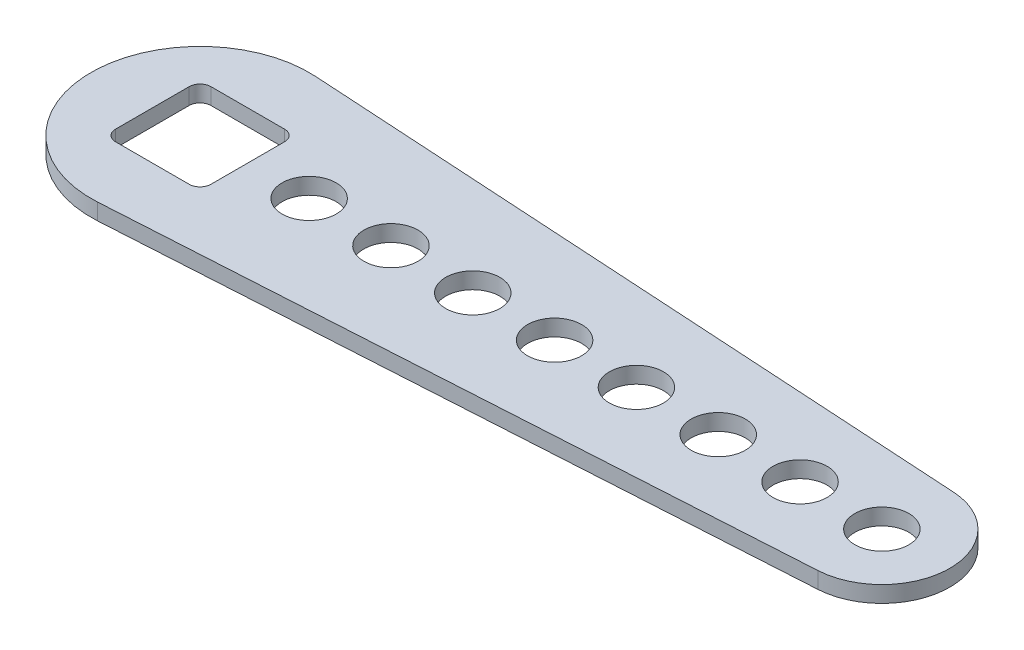
from build123d import *

# Parameters (mm, degrees)
SKETCH1_R           = 3.96875
BOSS_EXTRUDE1_DEPTH = 2.4


with BuildPart() as part:
    # Sketch1 → Boss-Extrude1 (new body)
    with BuildSketch(Plane(origin=(0, 0, 0), x_dir=(1, 0, 0), z_dir=(0, 1, 0))):
        with BuildLine():
            Line((0.965, 15.970872706), (100.601240234, 9.950602331))
            ThreePointArc((100.601240234, 9.950602331), (109.96875, 0), (100.601240234, -9.950602331))
            Line((100.601240234, -9.950602331), (0.965, -15.970872706))
            ThreePointArc((0.965, -15.970872706), (-16, 0), (0.965, 15.970872706))
        make_face()
        with Locations((16, 0)):
            Circle(SKETCH1_R, mode=Mode.SUBTRACT)
        with Locations((28, 0)):
            Circle(SKETCH1_R, mode=Mode.SUBTRACT)
        with Locations((40, 0)):
            Circle(SKETCH1_R, mode=Mode.SUBTRACT)
        with Locations((52, 0)):
            Circle(SKETCH1_R, mode=Mode.SUBTRACT)
        with Locations((64, 0)):
            Circle(SKETCH1_R, mode=Mode.SUBTRACT)
        with Locations((76, 0)):
            Circle(SKETCH1_R, mode=Mode.SUBTRACT)
        with Locations((88, 0)):
            Circle(SKETCH1_R, mode=Mode.SUBTRACT)
        with Locations((100, 0)):
            Circle(SKETCH1_R, mode=Mode.SUBTRACT)
        with BuildLine():
            Line((-5.4, 7), (5.4, 7))
            ThreePointArc((5.4, 7), (6.53137085, 6.53137085), (7, 5.4))
            Line((7, 5.4), (7, -5.4))
            ThreePointArc((7, -5.4), (6.53137085, -6.53137085), (5.4, -7))
            Line((5.4, -7), (-5.4, -7))
            ThreePointArc((-5.4, -7), (-6.53137085, -6.53137085), (-7, -5.4))
            Line((-7, -5.4), (-7, 5.4))
            ThreePointArc((-7, 5.4), (-6.53137085, 6.53137085), (-5.4, 7))
        make_face(mode=Mode.SUBTRACT)
    extrude(amount=BOSS_EXTRUDE1_DEPTH)


solid = part.part
